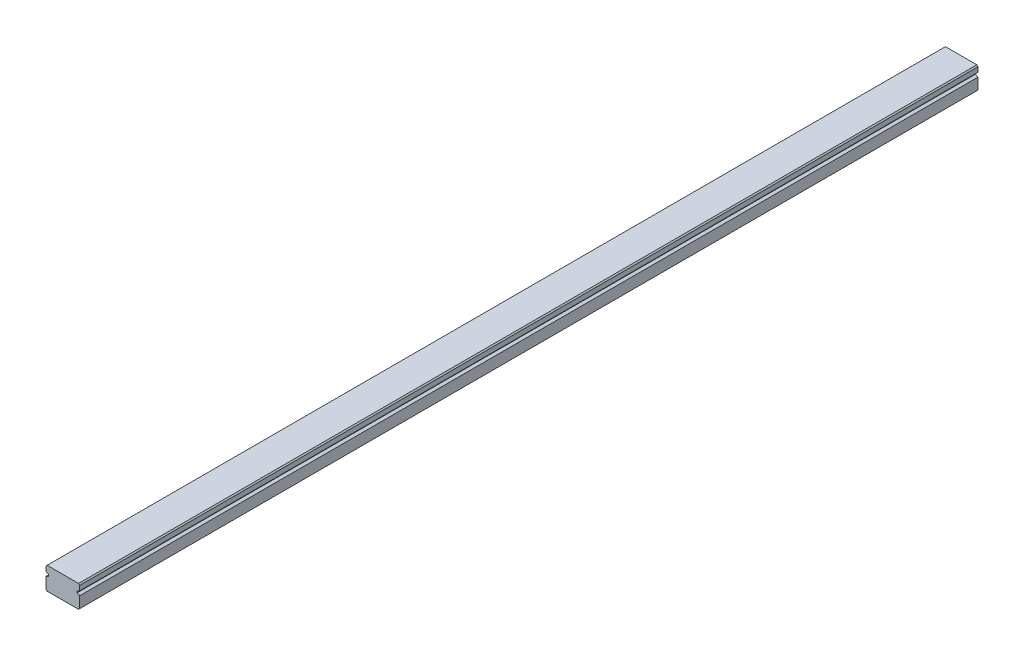
from build123d import *

# Parameters (mm, degrees)
EXTRUDE_1_DEPTH = 400


with BuildPart() as part:
    # 草图1 → 凸台-拉伸1 (new body)
    with BuildSketch(Plane.XY):
        Polygon((-3.269035533, 4.949238579), (10.730964467, 4.949238579), (11.230964467, 4.449238579), (11.230964467, 2.317517259), (10.086764657, 1.783377919), (10.086764657, 0.983377919), (11.230964467, 0.449238579), (11.230964467, -4.550761421), (10.730964467, -5.050761421), (-3.269035533, -5.050761421), (-3.769035533, -4.550761421), (-3.769035533, 0.449238579), (-2.624835723, 0.983377919), (-2.624835723, 1.783377919), (-3.769035533, 2.317517259), (-3.769035533, 4.449238579), align=None)
    extrude(amount=-EXTRUDE_1_DEPTH)


solid = part.part
